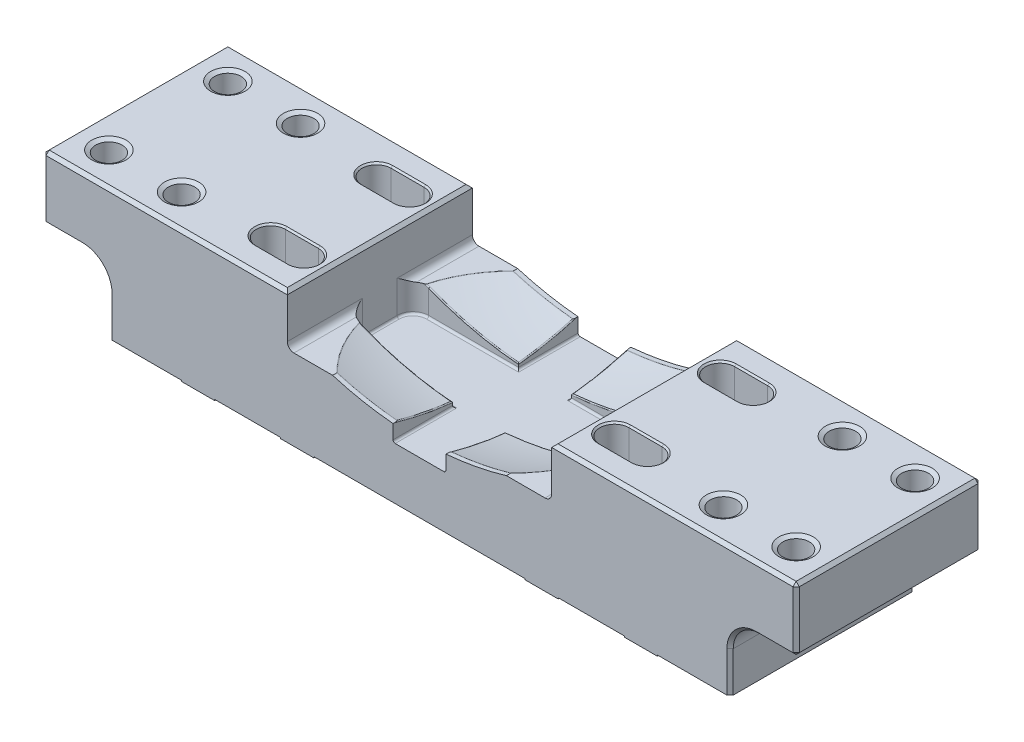
from build123d import *

# Parameters (mm, degrees)
SKETCH1_W                        = 361.95
SKETCH1_H                        = 63.5
EXTRUDE1_DEPTH                   = 44.45
SKETCH3_W                        = 127
SKETCH3_H                        = 9.118737669
EXTRUDE2_DEPTH                   = 45.45
EXTRUDE2_DEPTH_BACK              = 45.45
EXTRUDE4_DEPTH                   = 13.335
SKETCH5_W                        = 31.75
SKETCH5_H                        = 33.02
EXTRUDE5_DEPTH                   = 45.45
EXTRUDE5_DEPTH_BACK              = 45.45
EXTRUDE6_DEPTH                   = 1.016
FILLET1_R                        = 12.7
FILLET2_R                        = 7.62
FILLET3_R                        = 3.175
FILLET4_R                        = 1.016
F_1_2_13_TAPPED_HOLE1_AT_2_COUNT = 2
F_1_2_13_TAPPED_HOLE1_AT_2_PITCH = 57.15
F_1_2_13_TAPPED_HOLE1_AT_3_COUNT = 2
F_1_2_13_TAPPED_HOLE1_AT_3_PITCH = 66.976698373
F_1_2_13_TAPPED_HOLE1_AT_4_COUNT = 2
F_1_2_13_TAPPED_HOLE1_AT_4_PITCH = 34.925
F_1_2_13_TAPPED_HOLE1_AT_5_COUNT = 2
F_1_2_13_TAPPED_HOLE1_AT_5_PITCH = 335.10917997
F_1_2_13_TAPPED_HOLE1_AT_6_COUNT = 2
F_1_2_13_TAPPED_HOLE1_AT_6_PITCH = 300.754797343
F_1_2_13_TAPPED_HOLE1_AT_7_COUNT = 2
F_1_2_13_TAPPED_HOLE1_AT_7_PITCH = 295.275
F_1_2_13_TAPPED_HOLE1_AT_8_COUNT = 2
F_1_2_13_TAPPED_HOLE1_AT_8_PITCH = 330.2
EXTRUDE7_DEPTH                   = 64.5
EXTRUDE8_DEPTH                   = 45.4500001
EXTRUDE8_DEPTH_BACK              = 45.4500001
CHAMFER1_SIZE                    = 0.762
CHAMFER2_SIZE                    = 1.524
CHAMFER3_SIZE                    = 0.508
FILLET5_R                        = 0.508


with BuildPart() as part:
    # Sketch1 → Extrude1 (new body, symmetric)
    with BuildSketch(Plane.XY):
        with Locations((0, 31.75)):
            Rectangle(SKETCH1_W, SKETCH1_H)
    extrude(amount=EXTRUDE1_DEPTH, both=True)

    # Sketch2 → Cut-Revolve1 (revolve, cut)
    with BuildSketch(Plane.XY):
        with BuildLine():
            Line((-63.5, 41.164356144), (-63.5, 63.5))
            Line((-63.5, 63.5), (63.5, 63.5))
            Line((63.5, 63.5), (63.5, 41.164356144))
            ThreePointArc((63.5, 41.164356144), (0, 27.305), (-63.5, 41.164356144))
        make_face()
    revolve(axis=Axis((0, 179.705, 0), (1, 0, 0)), mode=Mode.SUBTRACT)

    # Sketch3 → Extrude2 (cut, two sides)
    with BuildSketch(Plane.XY) as extrude2_sk:
        with Locations((0, 43.929368835)):
            Rectangle(SKETCH3_W, SKETCH3_H)
    extrude(amount=EXTRUDE2_DEPTH, mode=Mode.SUBTRACT)
    extrude(extrude2_sk.sketch, amount=-EXTRUDE2_DEPTH_BACK, mode=Mode.SUBTRACT)

    # Sketch4 → Extrude4 (cut)
    with BuildSketch(Plane(origin=(0, 39.37, 0), x_dir=(1, 0, 0), z_dir=(0, 1, 0))):
        Polygon((-63.5, 15.875), (-63.5, -15.875), (-12.7, -15.875), (-12.7, -44.45), (12.7, -44.45), (12.7, -15.875), (63.5, -15.875), (63.5, 15.875), (12.7, 15.875), (12.7, 44.45), (-12.7, 44.45), (-12.7, 15.875), align=None)
    extrude(amount=-EXTRUDE4_DEPTH, mode=Mode.SUBTRACT)

    # Sketch5 → Extrude5 (cut, two sides)
    with BuildSketch(Plane.XY) as extrude5_sk:
        with Locations((-165.1, 16.51)):
            Rectangle(SKETCH5_W, SKETCH5_H)
        with Locations((165.1, 16.51)):
            Rectangle(SKETCH5_W, SKETCH5_H)
    extrude(amount=EXTRUDE5_DEPTH, mode=Mode.SUBTRACT)
    extrude(extrude5_sk.sketch, amount=-EXTRUDE5_DEPTH_BACK, mode=Mode.SUBTRACT)

    # Sketch6 → Extrude6 (cut)
    with BuildSketch(Plane.XZ):
        Polygon((-149.225, 44.45), (-149.225, -44.45), (-114.3, -44.45), (-114.3, -12.7), (-98.425, -12.7), (-98.425, -44.45), (-66.675, -44.45), (-66.675, -12.7), (-50.8, -12.7), (-50.8, -44.45), (50.8, -44.45), (50.8, -12.7), (66.675, -12.7), (66.675, -44.45), (98.425, -44.45), (98.425, -12.7), (114.3, -12.7), (114.3, -44.45), (149.225, -44.45), (149.225, 44.45), (114.3, 44.45), (114.3, 12.7), (98.425, 12.7), (98.425, 44.45), (66.675, 44.45), (66.675, 12.7), (50.8, 12.7), (50.8, 44.45), (-50.8, 44.45), (-50.8, 12.7), (-66.675, 12.7), (-66.675, 44.45), (-98.425, 44.45), (-98.425, 12.7), (-114.3, 12.7), (-114.3, 44.45), align=None)
    extrude(amount=-EXTRUDE6_DEPTH, mode=Mode.SUBTRACT)

    # Fillet1
    fillet1_edges = [part.edges().sort_by_distance(p)[0] for p in [
        (-149.225, 33.02, 0),
        (149.225, 33.02, 0),
    ]]
    fillet(fillet1_edges, radius=FILLET1_R)

    # Fillet2
    fillet2_edges = [part.edges().sort_by_distance(p)[0] for p in [
        (63.5, 32.7025, 15.875),
        (63.5, 32.7025, -15.875),
        (-63.5, 32.7025, 15.875),
        (-63.5, 32.7025, -15.875),
    ]]
    fillet(fillet2_edges, radius=FILLET2_R)

    # Fillet3
    fillet3_edges = [part.edges().sort_by_distance(p)[0] for p in [
        (-63.5, 39.37, -26.3525),
        (63.5, 39.37, -26.3525),
        (-63.5, 39.37, 26.3525),
        (63.5, 39.37, 26.3525),
    ]]
    fillet(fillet3_edges, radius=FILLET3_R)

    # Fillet4
    fillet4_edges = [part.edges().sort_by_distance(p)[0] for p in [
        (63.5, 26.035, 0),
        (-63.5, 26.035, 0),
        (-34.29, 26.035, 15.875),
        (34.29, 26.035, -15.875),
        (-61.268153673, 26.035, -13.643153673),
        (-61.268153673, 26.035, 13.643153673),
        (61.268153673, 26.035, -13.643153673),
        (61.268153673, 26.035, 13.643153673),
        (-12.7, 26.035, 30.1625),
        (12.7, 26.035, 30.1625),
        (12.7, 26.035, -30.1625),
        (-12.7, 26.035, -30.1625),
        (34.29, 26.035, 15.875),
        (-34.29, 26.035, -15.875),
    ]]
    fillet(fillet4_edges, radius=FILLET4_R)

    # Sketch7 → 1/2-13 Tapped Hole1 (revolve, cut)
    with BuildSketch(Plane(origin=(-165.1, 63.5, -28.575), x_dir=(0, 0, 1), z_dir=(1, 0, 0))):
        Polygon((0, 0), (0, 63.5), (5.35813, 63.5), (5.35813, 38.1), (6.35, 38.1), (6.35, 1.099852263), (8.255, 0), align=None)
    f_1_2_13_tapped_hole1 = revolve(axis=Axis((-165.1, 69.85, -28.575), (0, -1, 0)), mode=Mode.SUBTRACT)

    # 1/2-13 Tapped Hole1 at 2: 1/2-13 Tapped Hole1 ×2
    with Locations(*[(0, 0, i * F_1_2_13_TAPPED_HOLE1_AT_2_PITCH) for i in range(1, F_1_2_13_TAPPED_HOLE1_AT_2_COUNT)]):
        add(f_1_2_13_tapped_hole1, mode=Mode.SUBTRACT)

    # 1/2-13 Tapped Hole1 at 3: 1/2-13 Tapped Hole1 ×2
    with Locations(*[Vector(0.521450009, 0, 0.853281834) * (i * F_1_2_13_TAPPED_HOLE1_AT_3_PITCH) for i in range(1, F_1_2_13_TAPPED_HOLE1_AT_3_COUNT)]):
        add(f_1_2_13_tapped_hole1, mode=Mode.SUBTRACT)

    # 1/2-13 Tapped Hole1 at 4: 1/2-13 Tapped Hole1 ×2
    with Locations(*[(i * F_1_2_13_TAPPED_HOLE1_AT_4_PITCH, 0, 0) for i in range(1, F_1_2_13_TAPPED_HOLE1_AT_4_COUNT)]):
        add(f_1_2_13_tapped_hole1, mode=Mode.SUBTRACT)

    # 1/2-13 Tapped Hole1 at 5: 1/2-13 Tapped Hole1 ×2
    with Locations(*[Vector(0.985350506, 0, 0.170541434) * (i * F_1_2_13_TAPPED_HOLE1_AT_5_PITCH) for i in range(1, F_1_2_13_TAPPED_HOLE1_AT_5_COUNT)]):
        add(f_1_2_13_tapped_hole1, mode=Mode.SUBTRACT)

    # 1/2-13 Tapped Hole1 at 6: 1/2-13 Tapped Hole1 ×2
    with Locations(*[Vector(0.981779851, 0, 0.190021907) * (i * F_1_2_13_TAPPED_HOLE1_AT_6_PITCH) for i in range(1, F_1_2_13_TAPPED_HOLE1_AT_6_COUNT)]):
        add(f_1_2_13_tapped_hole1, mode=Mode.SUBTRACT)

    # 1/2-13 Tapped Hole1 at 7: 1/2-13 Tapped Hole1 ×2
    with Locations(*[(i * F_1_2_13_TAPPED_HOLE1_AT_7_PITCH, 0, 0) for i in range(1, F_1_2_13_TAPPED_HOLE1_AT_7_COUNT)]):
        add(f_1_2_13_tapped_hole1, mode=Mode.SUBTRACT)

    # 1/2-13 Tapped Hole1 at 8: 1/2-13 Tapped Hole1 ×2
    with Locations(*[(i * F_1_2_13_TAPPED_HOLE1_AT_8_PITCH, 0, 0) for i in range(1, F_1_2_13_TAPPED_HOLE1_AT_8_COUNT)]):
        add(f_1_2_13_tapped_hole1, mode=Mode.SUBTRACT)

    # Sketch9 → Extrude7 (cut, through all)
    with BuildSketch(Plane(origin=(0, 63.5, 0), x_dir=(1, 0, 0), z_dir=(0, 1, 0))):
        with BuildLine():
            Line((-90.4875, 32.385), (-74.6125, 32.385))
            ThreePointArc((-74.6125, 32.385), (-67.6275, 25.4), (-74.6125, 18.415))
            Line((-74.6125, 18.415), (-90.4875, 18.415))
            ThreePointArc((-90.4875, 18.415), (-97.4725, 25.4), (-90.4875, 32.385))
        make_face()
        with BuildLine():
            Line((-90.4875, -18.415), (-74.6125, -18.415))
            ThreePointArc((-74.6125, -18.415), (-67.6275, -25.4), (-74.6125, -32.385))
            Line((-74.6125, -32.385), (-90.4875, -32.385))
            ThreePointArc((-90.4875, -32.385), (-97.4725, -25.4), (-90.4875, -18.415))
        make_face()
        with BuildLine():
            Line((74.6125, 32.385), (90.4875, 32.385))
            ThreePointArc((90.4875, 32.385), (97.4725, 25.4), (90.4875, 18.415))
            Line((90.4875, 18.415), (74.6125, 18.415))
            ThreePointArc((74.6125, 18.415), (67.6275, 25.4), (74.6125, 32.385))
        make_face()
        with BuildLine():
            Line((74.6125, -18.415), (90.4875, -18.415))
            ThreePointArc((90.4875, -18.415), (97.4725, -25.4), (90.4875, -32.385))
            Line((90.4875, -32.385), (74.6125, -32.385))
            ThreePointArc((74.6125, -32.385), (67.6275, -25.4), (74.6125, -18.415))
        make_face()
    extrude(amount=-EXTRUDE7_DEPTH, mode=Mode.SUBTRACT)

    # Sketch10 → Extrude8 (cut, two sides)
    with BuildSketch(Plane.XY) as extrude8_sk:
        with BuildLine():
            Line((-41.755004299, 39.37), (41.755004299, 39.37))
            ThreePointArc((41.755004299, 39.37), (0, 33.274), (-41.755004299, 39.37))
        make_face()
    extrude(amount=EXTRUDE8_DEPTH, mode=Mode.SUBTRACT)
    extrude(extrude8_sk.sketch, amount=-EXTRUDE8_DEPTH_BACK, mode=Mode.SUBTRACT)

    # Chamfer1
    chamfer1_edges = [part.edges().sort_by_distance(p)[0] for p in [
        (-97.4725, 63.5, -25.4),
        (-82.55, 63.5, -18.415),
        (-67.6275, 63.5, -25.4),
        (-82.55, 63.5, -32.385),
        (-97.4725, 63.5, 25.4),
        (-82.55, 63.5, 32.385),
        (-67.6275, 63.5, 25.4),
        (-82.55, 63.5, 18.415),
        (67.6275, 63.5, -25.4),
        (82.55, 63.5, -18.415),
        (97.4725, 63.5, -25.4),
        (82.55, 63.5, -32.385),
        (67.6275, 63.5, 25.4),
        (82.55, 63.5, 32.385),
        (97.4725, 63.5, 25.4),
        (82.55, 63.5, 18.415),
    ]]
    chamfer(chamfer1_edges, length=CHAMFER1_SIZE)

    # Chamfer2
    chamfer2_edges = [part.edges().sort_by_distance(p)[0] for p in [
        (-180.975, 33.02, 0),
        (180.975, 48.26, -44.45),
        (180.975, 48.26, 44.45),
        (180.975, 33.02, 0),
        (171.45, 33.02, -44.45),
        (171.45, 33.02, 44.45),
        (122.2375, 63.5, 44.45),
        (-149.225, 10.668, -44.45),
        (-149.225, 10.668, 44.45),
        (-122.2375, 63.5, -44.45),
        (-122.2375, 63.5, 44.45),
        (63.5, 63.5, 0),
        (-63.5, 63.5, 0),
        (149.225, 10.668, -44.45),
        (149.225, 10.668, 44.45),
        (-171.45, 33.02, -44.45),
        (-171.45, 33.02, 44.45),
        (152.944743879, 29.300256121, 44.45),
        (152.944743879, 29.300256121, -44.45),
        (-152.944743879, 29.300256121, 44.45),
        (-152.944743879, 29.300256121, -44.45),
        (-180.975, 48.26, 44.45),
        (122.2375, 63.5, -44.45),
        (-180.975, 48.26, -44.45),
        (-180.975, 63.5, 0),
        (180.975, 63.5, 0),
    ]]
    chamfer(chamfer2_edges, length=CHAMFER2_SIZE)

    # Chamfer3
    chamfer3_edges = [part.edges().sort_by_distance(p)[0] for p in [
        (-106.3625, 0, -44.45),
        (-58.7375, 0, -44.45),
        (58.7375, 0, -44.45),
        (106.3625, 0, -44.45),
        (-106.3625, 0, 44.45),
        (-58.7375, 0, 44.45),
        (58.7375, 0, 44.45),
        (106.3625, 0, 44.45),
        (-114.3, 0, -28.575),
        (-106.3625, 0, -12.7),
        (-98.425, 0, -28.575),
        (-66.675, 0, -28.575),
        (-58.7375, 0, -12.7),
        (-50.8, 0, -28.575),
        (50.8, 0, -28.575),
        (58.7375, 0, -12.7),
        (66.675, 0, -28.575),
        (98.425, 0, -28.575),
        (106.3625, 0, -12.7),
        (114.3, 0, -28.575),
        (114.3, 0, 28.575),
        (106.3625, 0, 12.7),
        (98.425, 0, 28.575),
        (66.675, 0, 28.575),
        (58.7375, 0, 12.7),
        (50.8, 0, 28.575),
        (-50.8, 0, 28.575),
        (-58.7375, 0, 12.7),
        (-66.675, 0, 28.575),
        (-98.425, 0, 28.575),
        (-106.3625, 0, 12.7),
        (-114.3, 0, 28.575),
    ]]
    chamfer(chamfer3_edges, length=CHAMFER3_SIZE)

    # Fillet5
    fillet5_edges = [part.edges().sort_by_distance(p)[0] for p in [
        (34.663063676, 32.150886565, 15.875),
        (-34.663063676, 32.150886565, -15.875),
        (56.59569046, 39.092978695, 15.841315783),
        (56.59569046, 39.092978695, -15.841315783),
        (-56.59569046, 39.092978695, 15.841315783),
        (-56.59569046, 39.092978695, -15.841315783),
        (12.7, 30.663058571, -29.171384866),
        (-12.7, 30.663058571, 29.171384866),
        (-51.278964169, 39.37, -30.038568687),
        (51.278964169, 39.37, 30.038568687),
        (-27.368194547, 35.861167088, 42.257468693),
        (27.368194547, 35.861167088, 42.257468693),
        (27.368194547, 35.861167088, -42.257468693),
        (-27.368194547, 35.861167088, -42.257468693),
        (-51.278964169, 39.37, 30.038568687),
        (51.278964169, 39.37, -30.038568687),
        (-12.7, 30.663058571, -29.171384866),
        (12.7, 30.663058571, 29.171384866),
        (34.663063676, 32.150886565, -15.875),
        (-34.663063676, 32.150886565, 15.875),
    ]]
    fillet(fillet5_edges, radius=FILLET5_R)


solid = part.part
